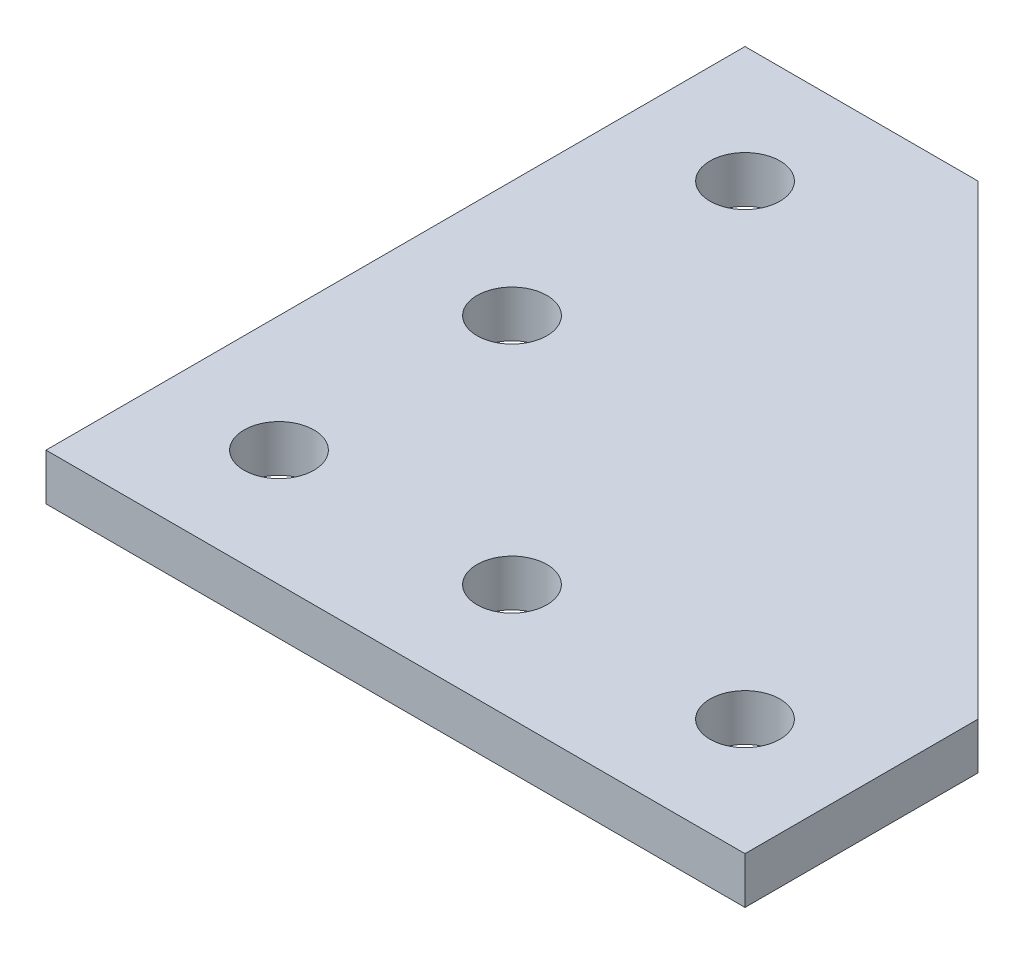
from build123d import *

# Parameters (mm, degrees)
BOSS_EXTRUDE1_DEPTH = 4
SKETCH3_R           = 3
CUT_EXTRUDE1_DEPTH  = 5


with BuildPart() as part:
    # Sketch2 → Boss-Extrude1 (new body)
    with BuildSketch(Plane(origin=(0, 0, 0), x_dir=(1, 0, 0), z_dir=(0, 1, 0))):
        Polygon((0, 0), (0, 60), (20, 60), (60, 20), (60, 0), align=None)
    extrude(amount=BOSS_EXTRUDE1_DEPTH)

    # Sketch3 → Cut-Extrude1 (cut, through all)
    with BuildSketch(Plane(origin=(0, 4, 0), x_dir=(1, 0, 0), z_dir=(0, 1, 0))):
        with Locations((10, 10)):
            Circle(SKETCH3_R)
        with Locations((30, 10)):
            Circle(SKETCH3_R)
        with Locations((50, 10)):
            Circle(SKETCH3_R)
        with Locations((10, 50)):
            Circle(SKETCH3_R)
        with Locations((10, 30)):
            Circle(SKETCH3_R)
    extrude(amount=-CUT_EXTRUDE1_DEPTH, mode=Mode.SUBTRACT)


solid = part.part
